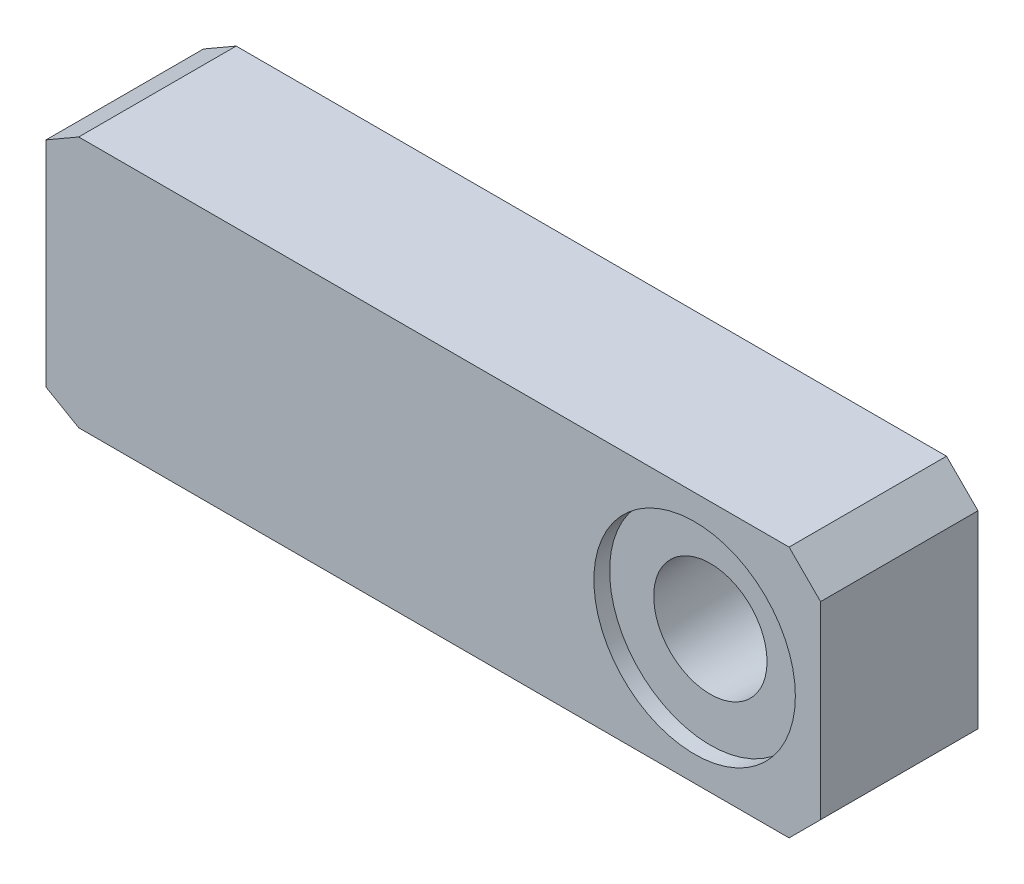
from build123d import *

# Parameters (mm, degrees)
SKIZZE1_W                       = 123
SKIZZE1_H                       = 40
AUFSATZ_LINEAR_AUSTRAGEN1_DEPTH = 12.5
FASE_3X60_SIZE                  = 3
FASE_3X60_SIZE2                 = 5.196152423
FASE_5X45_SIZE                  = 5


with BuildPart() as part:
    # Skizze1 → Aufsatz-Linear austragen1 (new body, symmetric)
    with BuildSketch(Plane.XY):
        with Locations((61.5, 0)):
            Rectangle(SKIZZE1_W, SKIZZE1_H)
    extrude(amount=AUFSATZ_LINEAR_AUSTRAGEN1_DEPTH, both=True)

    # Skizze2 → Bohrung_Kegel 1_10 (revolve, cut)
    with BuildSketch(Plane(origin=(0, 0, 0), x_dir=(1, 0, 0), z_dir=(0, 1, 0)), mode=Mode.PRIVATE) as bohrung_kegel_1_10_sk:
        Polygon((103, -12.5), (87, -12.5), (87, -10), (94, -10), (93, 10), (87, 10), (87, 12.5), (103, 12.5), align=None)
    revolve(bohrung_kegel_1_10_sk.sketch.rotate(Axis((103, 0, 15.136672695), (0, 0, -1)), 180), axis=Axis((103, 0, 15.136672695), (0, 0, -1)), mode=Mode.SUBTRACT)  # turned: the seam where the file's is

    # Fase 3x60
    fase_3x60_edges = [part.edges().sort_by_distance(p)[0] for p in [
        (0, 20, 0),
        (0, -20, 0),
    ]]
    fase_3x60_side = [part.faces().sort_by_distance(p)[0] for p in [
        (0, 0, 0),
    ]]
    chamfer(fase_3x60_edges, length=FASE_3X60_SIZE, length2=FASE_3X60_SIZE2, reference=fase_3x60_side[0])

    # Fase 5x45
    fase_5x45_edges = [part.edges().sort_by_distance(p)[0] for p in [
        (123, 20, 0),
        (123, -20, 0),
    ]]
    chamfer(fase_5x45_edges, length=FASE_5X45_SIZE)


solid = part.part
